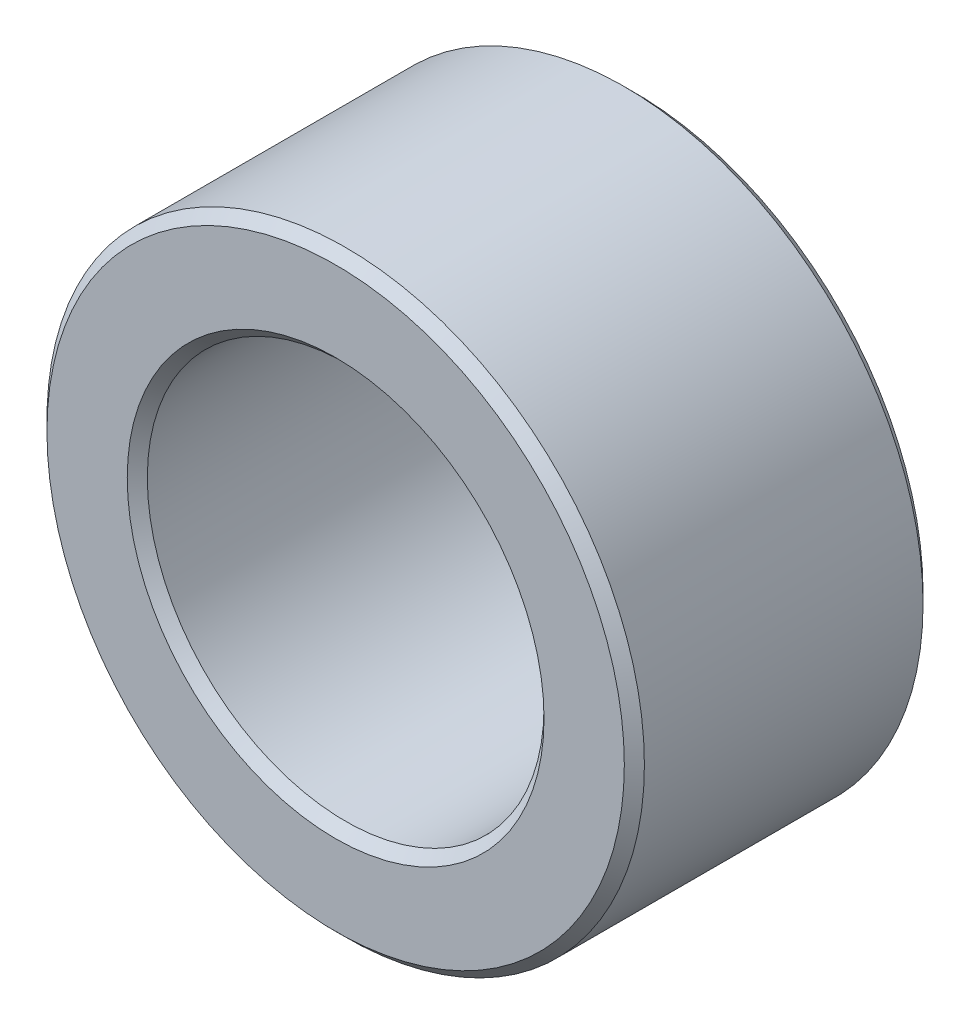
from build123d import *

# Parameters (mm, degrees)
BOSS_EXTRUDE1_DEPTH      = 1.5875
BOSS_EXTRUDE1_DEPTH_BACK = 1.5875
SKETCH3_R                = 3.175
SKETCH3_R_2              = 2.1082
CHAMFER1_SIZE            = 0.10668


with BuildPart() as part:
    # Sketch3 → Boss-Extrude1 (new, two sides: drawn at the far end of the back side and taken through both)
    with BuildSketch(Plane.XY.offset(-BOSS_EXTRUDE1_DEPTH_BACK)):
        Circle(SKETCH3_R)
        Circle(SKETCH3_R_2, mode=Mode.SUBTRACT)
    extrude(amount=BOSS_EXTRUDE1_DEPTH + BOSS_EXTRUDE1_DEPTH_BACK)

    # Chamfer1
    chamfer1_edges = [part.edges().sort_by_distance(p)[0] for p in [
        (-3.175, 0, -1.5875),
        (-2.1082, 0, -1.5875),
        (-3.175, 0, 1.5875),
        (-2.1082, 0, 1.5875),
    ]]
    chamfer(chamfer1_edges, length=CHAMFER1_SIZE)


solid = part.part
